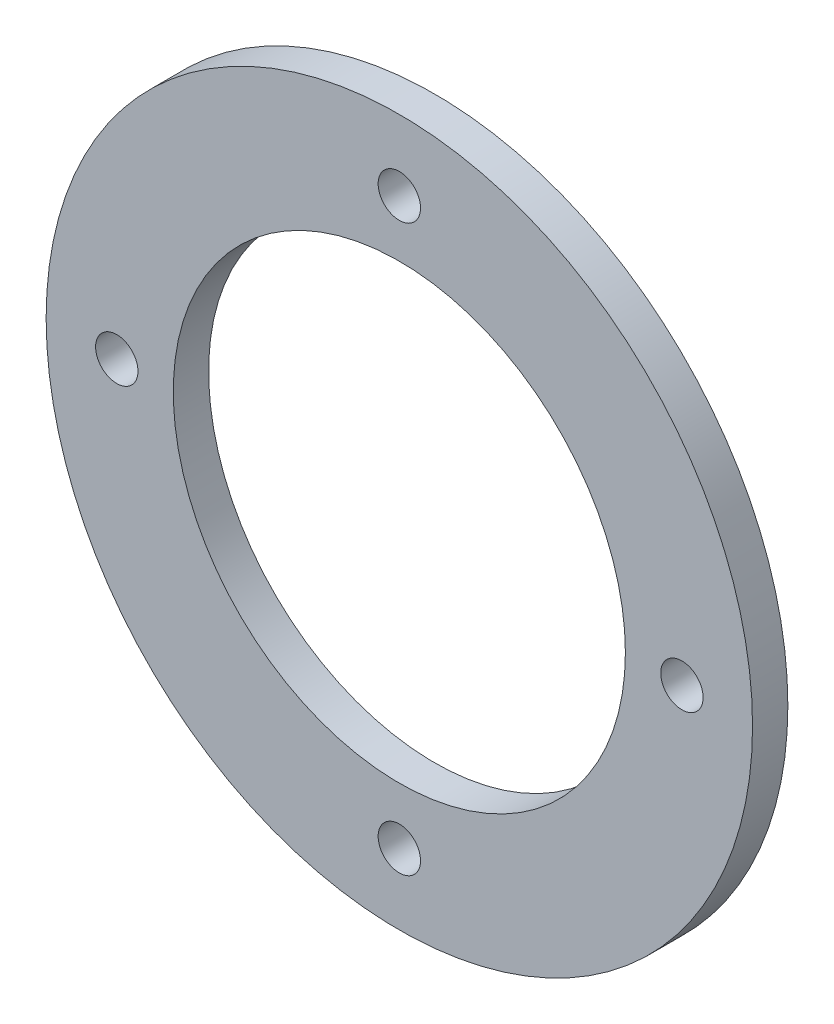
from build123d import *

# Parameters (mm, degrees)
SZKIC1_R                    = 50
DODANIE_WYCI_GNI_CIE1_DEPTH = 5
SZKIC2_R                    = 32
WYTNIJ_WYCI_GNI_CIE1_DEPTH  = 5
SZKIC3_R                    = 3
WYTNIJ_WYCI_GNI_CIE2_DEPTH  = 5


with BuildPart() as part:
    # Szkic1 → Dodanie-wyciągnięcie1 (new body)
    with BuildSketch(Plane.XY):
        Circle(SZKIC1_R)
    extrude(amount=DODANIE_WYCI_GNI_CIE1_DEPTH)

    # Szkic2 → Wytnij-wyciągnięcie1 (cut)
    with BuildSketch(Plane.XY.offset(5)):
        Circle(SZKIC2_R)
    extrude(amount=-WYTNIJ_WYCI_GNI_CIE1_DEPTH, mode=Mode.SUBTRACT)

    # Szkic3 → Wytnij-wyciągnięcie2 (cut)
    with BuildSketch(Plane.XY.offset(5)):
        with Locations((0, 40)):
            Circle(SZKIC3_R)
        with Locations((40, 0)):
            Circle(SZKIC3_R)
        with Locations((0, -40)):
            Circle(SZKIC3_R)
        with Locations((-40, 0)):
            Circle(SZKIC3_R)
    extrude(amount=-WYTNIJ_WYCI_GNI_CIE2_DEPTH, mode=Mode.SUBTRACT)


solid = part.part
